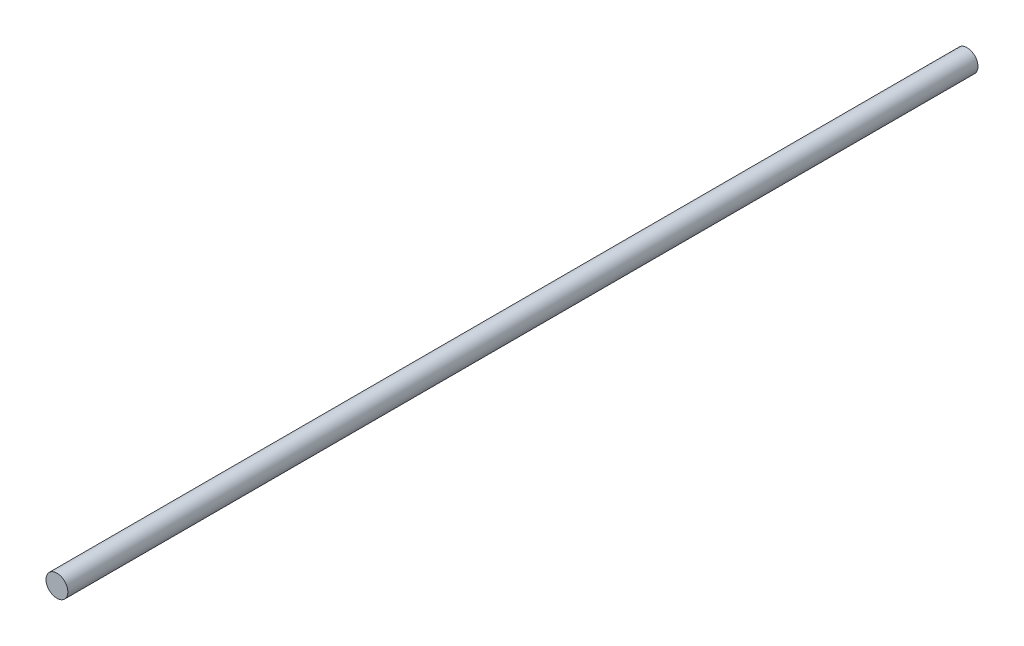
from build123d import *

# Parameters (mm, degrees)
SKETCH1_R           = 3
BOSS_EXTRUDE1_DEPTH = 250


with BuildPart() as part:
    # Sketch1 → Boss-Extrude1 (new body)
    with BuildSketch(Plane.XY):
        Circle(SKETCH1_R)
    extrude(amount=BOSS_EXTRUDE1_DEPTH)


solid = part.part
